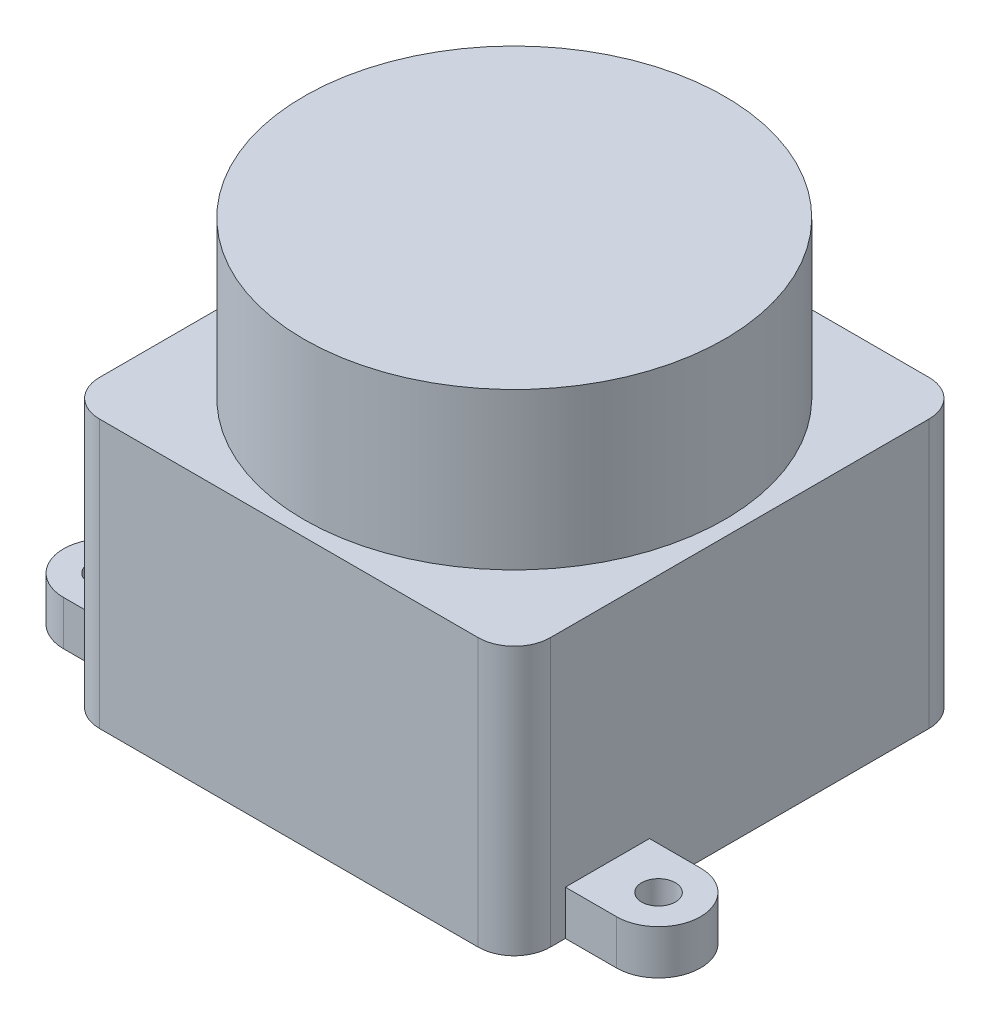
from build123d import *

# Parameters (mm, degrees)
ESQUISSE1_W        = 37.5
ESQUISSE1_H        = 37.5
BOSS_EXTRU_1_DEPTH = 22.3
CONG_1_R           = 3
ESQUISSE2_R        = 17.5
BOSS_EXTRU_2_DEPTH = 13
ESQUISSE3_R        = 1.4
BOSS_EXTRU_3_DEPTH = 3.7


with BuildPart() as part:
    # Esquisse1 → Boss.-Extru.1 (new body)
    with BuildSketch(Plane(origin=(0, 0, 0), x_dir=(1, 0, 0), z_dir=(0, 1, 0))):
        Rectangle(ESQUISSE1_W, ESQUISSE1_H)
    extrude(amount=BOSS_EXTRU_1_DEPTH)

    # Congé1
    cong_1_edges = [part.edges().sort_by_distance(p)[0] for p in [
        (18.75, 11.15, 18.75),
        (-18.75, 11.15, 18.75),
        (-18.75, 11.15, -18.75),
        (18.75, 11.15, -18.75),
    ]]
    fillet(cong_1_edges, radius=CONG_1_R)

    # Esquisse2 → Boss.-Extru.2 (add)
    with BuildSketch(Plane(origin=(0, 22.3, 0), x_dir=(1, 0, 0), z_dir=(0, 1, 0))):
        Circle(ESQUISSE2_R)
    extrude(amount=BOSS_EXTRU_2_DEPTH)

    # Esquisse3 → Boss.-Extru.3 (add)
    with BuildSketch(Plane.XZ):
        with BuildLine():
            Line((-18.75, 14.5), (-23, 14.5))
            ThreePointArc((-23, 14.5), (-26.5, 11), (-23, 7.5))
            Line((-23, 7.5), (-18.75, 7.5))
            Line((-18.75, 7.5), (-18.75, 14.5))
        make_face()
        with Locations((-23, 11)):
            Circle(ESQUISSE3_R, mode=Mode.SUBTRACT)
        with BuildLine():
            Line((18.75, 7.5), (23, 7.5))
            ThreePointArc((23, 7.5), (26.5, 11), (23, 14.5))
            Line((23, 14.5), (18.75, 14.5))
            Line((18.75, 14.5), (18.75, 7.5))
        make_face()
        with Locations((23, 11)):
            Circle(ESQUISSE3_R, mode=Mode.SUBTRACT)
        with BuildLine():
            ThreePointArc((-3.5, -21.726136344), (0, -25.226136344), (3.5, -21.726136344))
            Line((3.5, -21.726136344), (3.5, -18.75))
            Line((3.5, -18.75), (-3.5, -18.75))
            Line((-3.5, -18.75), (-3.5, -21.726136344))
        make_face()
        with Locations((0, -21.726136344)):
            Circle(ESQUISSE3_R, mode=Mode.SUBTRACT)
    extrude(amount=-BOSS_EXTRU_3_DEPTH)


solid = part.part
